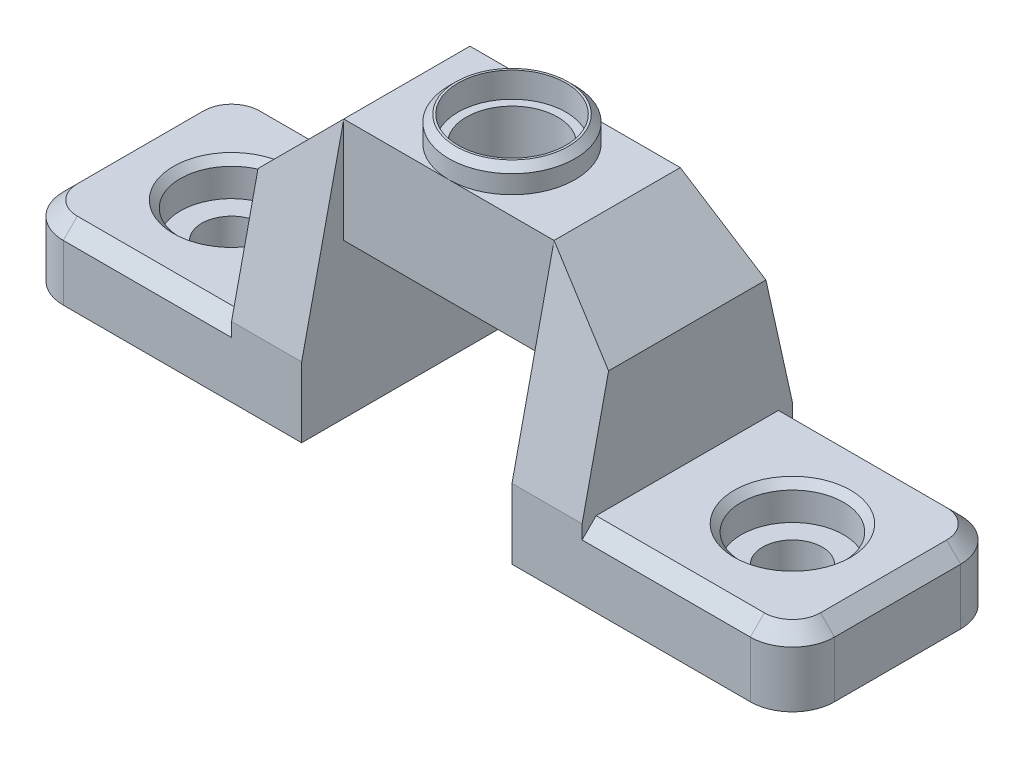
from build123d import *

# Parameters (mm, degrees)
BOSS_EXTRUDE1_DEPTH = 15
SKETCH2_W           = 25
SKETCH2_H           = 13.5
CUT_EXTRUDE1_DEPTH  = 3
SKETCH3_W           = 25
SKETCH3_H           = 13.5
CUT_EXTRUDE2_DEPTH  = 3
BOSS_EXTRUDE2_DEPTH = 5
BOSS_EXTRUDE3_DEPTH = 5
SKETCH6_R           = 3.25
CUT_EXTRUDE3_DEPTH  = 8.5
SKETCH7_R           = 2.125
CUT_EXTRUDE4_DEPTH  = 5
SKETCH8_R           = 3.65
CUT_EXTRUDE5_DEPTH  = 2.5
CHAMFER3_SIZE       = 0.5
FILLET1_R           = 3
SKETCH9_R           = 4.5
SKETCH9_R_2         = 3.85
BOSS_EXTRUDE4_DEPTH = 1.8
CHAMFER4_SIZE       = 5
CHAMFER5_SIZE       = 1
CHAMFER6_SIZE       = 0.5


with BuildPart() as part:
    # Sketch1 → Boss-Extrude1 (new body)
    with BuildSketch(Plane.XY):
        Polygon((0, 0), (20, 0), (20, 10), (35, 10), (35, 0), (55, 0), (55, 5), (40, 5), (40, 18.5), (15, 18.5), (15, 5), (0, 5), align=None)
    extrude(amount=BOSS_EXTRUDE1_DEPTH)

    # Sketch2 → Cut-Extrude1 (cut)
    with BuildSketch(Plane.XY.offset(15)):
        with Locations((27.5, 11.75)):
            Rectangle(SKETCH2_W, SKETCH2_H)
    extrude(amount=-CUT_EXTRUDE1_DEPTH, mode=Mode.SUBTRACT)

    # Sketch3 → Cut-Extrude2 (cut)
    with BuildSketch(Plane(origin=(0, 0, 0), x_dir=(-1, 0, 0), z_dir=(0, 0, -1))):
        with Locations((-27.5, 11.75)):
            Rectangle(SKETCH3_W, SKETCH3_H)
    extrude(amount=-CUT_EXTRUDE2_DEPTH, mode=Mode.SUBTRACT)

    # Sketch4 → Boss-Extrude2 (add)
    with BuildSketch(Plane(origin=(20, 0, 0), x_dir=(0, 0, -1), z_dir=(1, 0, 0))):
        Polygon((-12, 18.5), (-15, 5), (-12, 5), align=None)
        Polygon((-3, 5), (0, 5), (-3, 18.5), align=None)
    extrude(amount=-BOSS_EXTRUDE2_DEPTH)

    # Sketch5 → Boss-Extrude3 (add)
    with BuildSketch(Plane.ZY.offset(-35)):
        Polygon((0, 5), (3, 18.5), (3, 5), align=None)
        Polygon((12, 18.5), (12, 5), (15, 5), align=None)
    extrude(amount=-BOSS_EXTRUDE3_DEPTH)

    # Sketch6 → Cut-Extrude3 (cut)
    with BuildSketch(Plane(origin=(0, 18.5, 0), x_dir=(1, 0, 0), z_dir=(0, 1, 0))):
        with Locations((27.5, -7.5)):
            Circle(SKETCH6_R)
    extrude(amount=-CUT_EXTRUDE3_DEPTH, mode=Mode.SUBTRACT)

    # Sketch7 → Cut-Extrude4 (cut)
    with BuildSketch(Plane(origin=(0, 5, 0), x_dir=(1, 0, 0), z_dir=(0, 1, 0))):
        with Locations((7.5, -7.5)):
            Circle(SKETCH7_R)
        with Locations((47.5, -7.5)):
            Circle(SKETCH7_R)
    extrude(amount=-CUT_EXTRUDE4_DEPTH, mode=Mode.SUBTRACT)

    # Sketch8 → Cut-Extrude5 (cut)
    with BuildSketch(Plane(origin=(0, 5, 0), x_dir=(1, 0, 0), z_dir=(0, 1, 0))):
        with Locations((7.5, -7.5)):
            Circle(SKETCH8_R)
        with Locations((47.5, -7.5)):
            Circle(SKETCH8_R)
    extrude(amount=-CUT_EXTRUDE5_DEPTH, mode=Mode.SUBTRACT)

    # Chamfer3
    chamfer3_edges = [part.edges().sort_by_distance(p)[0] for p in [
        (3.85, 5, 7.5),
        (43.85, 5, 7.5),
    ]]
    chamfer(chamfer3_edges, length=CHAMFER3_SIZE)

    # Fillet1
    fillet1_edges = [part.edges().sort_by_distance(p)[0] for p in [
        (55, 2.5, 0),
        (0, 2.5, 0),
        (55, 2.5, 15),
        (0, 2.5, 15),
    ]]
    fillet(fillet1_edges, radius=FILLET1_R)

    # Sketch9 → Boss-Extrude4 (add)
    with BuildSketch(Plane(origin=(0, 18.5, 0), x_dir=(1, 0, 0), z_dir=(0, 1, 0))):
        with Locations((27.5, -7.5)):
            Circle(SKETCH9_R)
        with Locations((27.5, -7.5)):
            Circle(SKETCH9_R_2, mode=Mode.SUBTRACT)
    extrude(amount=BOSS_EXTRUDE4_DEPTH)

    # Chamfer4
    chamfer4_edges = [part.edges().sort_by_distance(p)[0] for p in [
        (40, 18.5, 7.5),
        (15, 18.5, 7.5),
    ]]
    chamfer(chamfer4_edges, length=CHAMFER4_SIZE)

    # Chamfer5
    chamfer5_edges = [part.edges().sort_by_distance(p)[0] for p in [
        (0, 5, 7.5),
        (0.878679656, 5, 14.121320344),
        (0.878679656, 5, 0.878679656),
        (55, 5, 7.5),
        (46, 5, 15),
        (46, 5, 0),
        (54.121320344, 5, 14.121320344),
        (54.121320344, 5, 0.878679656),
        (27.5, 10, 12),
        (27.5, 10, 3),
        (9, 5, 15),
        (9, 5, 0),
    ]]
    chamfer(chamfer5_edges, length=CHAMFER5_SIZE)

    # Chamfer6
    chamfer6_edges = [part.edges().sort_by_distance(p)[0] for p in [
        (23, 20.3, 7.5),
    ]]
    chamfer(chamfer6_edges, length=CHAMFER6_SIZE)


solid = part.part
